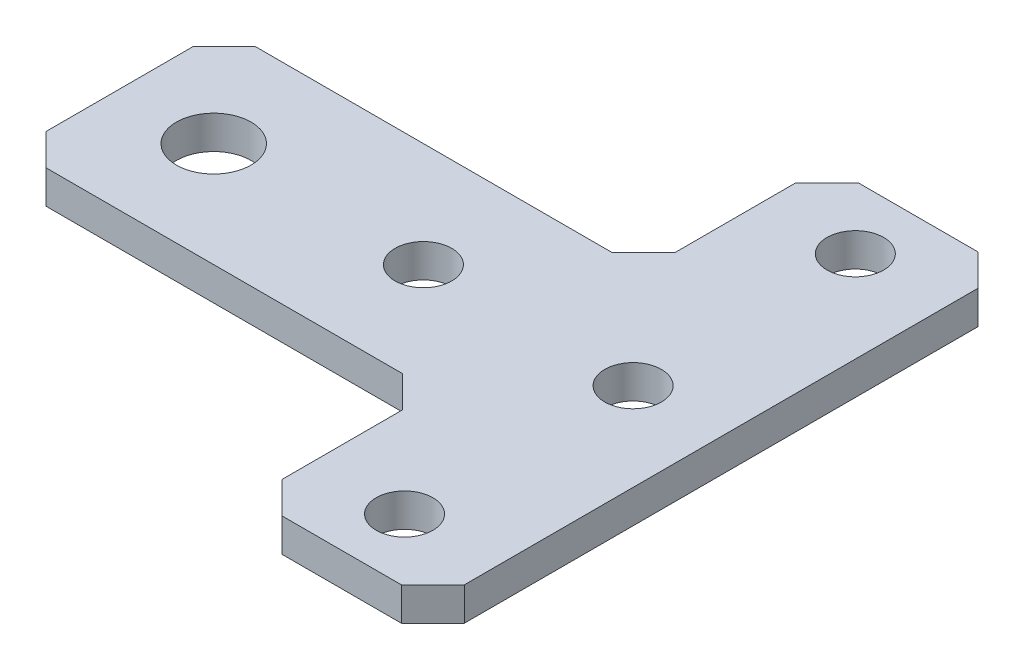
from build123d import *

# Parameters (mm, degrees)
SKETCH1_R           = 2.7
SKETCH1_R_2         = 3.56
BOSS_EXTRUDE1_DEPTH = 3.175
CHAMFER1_SIZE       = 3
CHAMFER2_SIZE       = 3


with BuildPart() as part:
    # Sketch1 → Boss-Extrude1 (new body)
    with BuildSketch(Plane(origin=(0, 0, 0), x_dir=(1, 0, 0), z_dir=(0, 1, 0))):
        Polygon((0, 0), (40, 0), (40, -17.5), (57.4, -17.5), (57.4, 37.5), (40, 37.5), (40, 20), (0, 20), align=None)
        with Locations((29, 10)):
            Circle(SKETCH1_R, mode=Mode.SUBTRACT)
        with Locations((9, 10)):
            Circle(SKETCH1_R_2, mode=Mode.SUBTRACT)
        with Locations((48.7, 31.5)):
            Circle(SKETCH1_R, mode=Mode.SUBTRACT)
        with Locations((48.7, -11.5)):
            Circle(SKETCH1_R, mode=Mode.SUBTRACT)
        with Locations((49, 10)):
            Circle(SKETCH1_R, mode=Mode.SUBTRACT)
    extrude(amount=BOSS_EXTRUDE1_DEPTH)

    # Chamfer1
    chamfer1_edges = [part.edges().sort_by_distance(p)[0] for p in [
        (0, 1.5875, -20),
        (40, 1.5875, -37.5),
        (57.4, 1.5875, -37.5),
        (57.4, 1.5875, 17.5),
        (40, 1.5875, 17.5),
        (0, 1.5875, 0),
    ]]
    chamfer(chamfer1_edges, length=CHAMFER1_SIZE)

    # Chamfer2
    chamfer2_edges = [part.edges().sort_by_distance(p)[0] for p in [
        (40, 1.5875, -20),
        (40, 1.5875, 0),
    ]]
    chamfer(chamfer2_edges, length=CHAMFER2_SIZE)


solid = part.part
